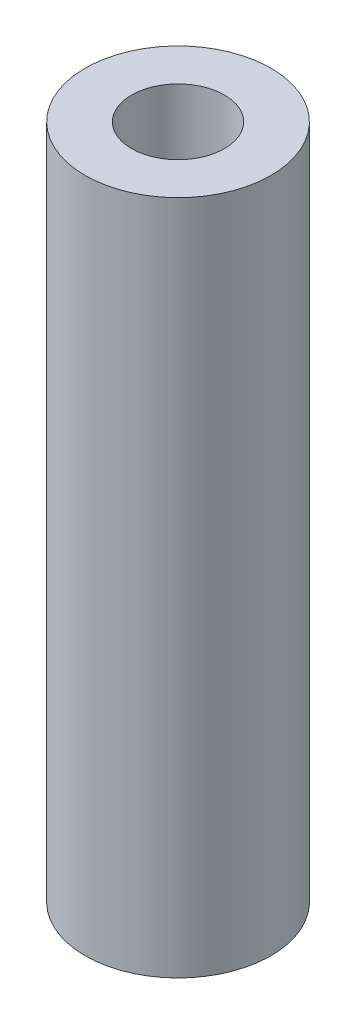
from build123d import *

# Parameters (mm, degrees)
SKETCH1_R           = 11
SKETCH1_R_2         = 5.5
BOSS_EXTRUDE1_DEPTH = 40


with BuildPart() as part:
    # Sketch1 → Boss-Extrude1 (new body, symmetric)
    with BuildSketch(Plane(origin=(0, 0, 0), x_dir=(1, 0, 0), z_dir=(0, 1, 0))):
        Circle(SKETCH1_R)
        Circle(SKETCH1_R_2, mode=Mode.SUBTRACT)
    extrude(amount=BOSS_EXTRUDE1_DEPTH, both=True)


solid = part.part
